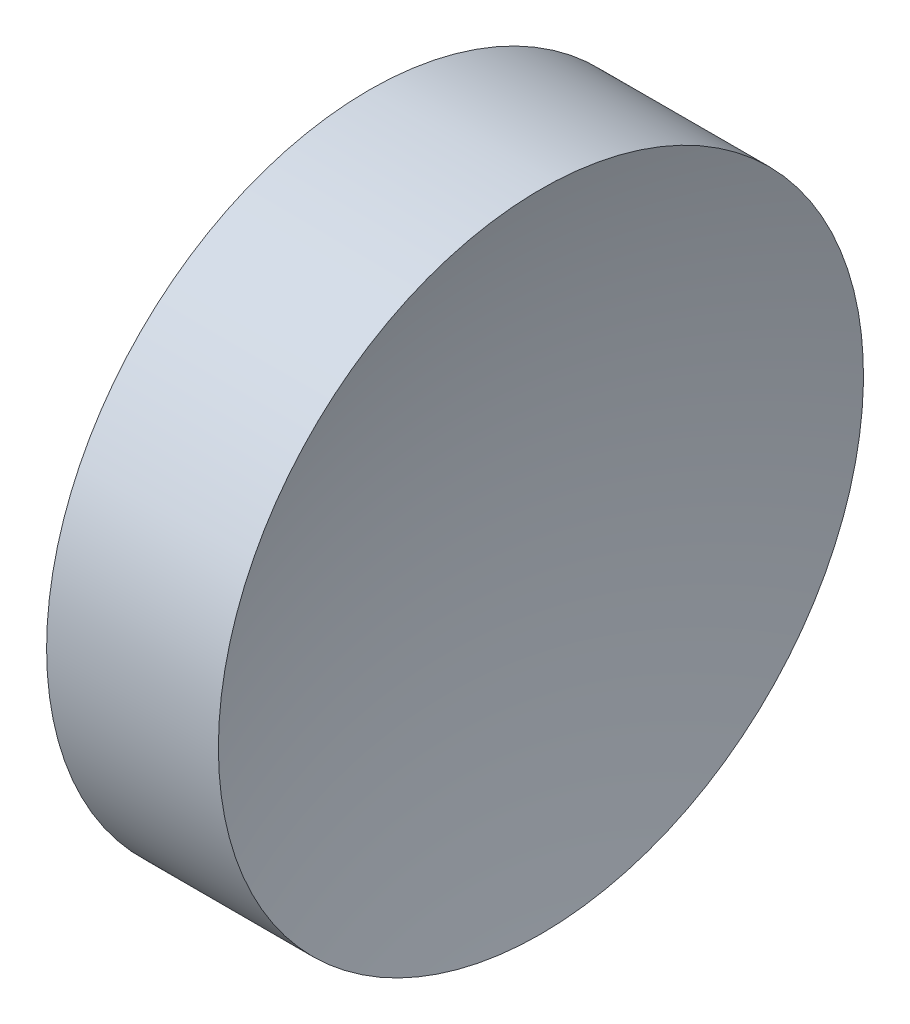
from build123d import *


with BuildPart() as part:
    # 草图2 → 旋转1 (revolve)
    with BuildSketch(Plane.XY, mode=Mode.PRIVATE) as revolve_1_sk:
        with BuildLine():
            Line((94.590443968, 52.178082298), (97.590443968, 52.178082298))
            ThreePointArc((97.590443968, 52.178082298), (98.063404259, 58.597399239), (99.472070908, 64.878082298))
            Line((99.472070908, 64.878082298), (96.090443968, 64.878082298))
            Line((96.090443968, 64.878082298), (92.708817028, 64.878082298))
            ThreePointArc((92.708817028, 64.878082298), (94.117483678, 58.597399239), (94.590443968, 52.178082298))
        make_face()
    revolve(revolve_1_sk.sketch.rotate(Axis((84.899722228, 52.178082298, 0), (1, 0, 0)), 90), axis=Axis((84.899722228, 52.178082298, 0), (1, 0, 0)))  # turned: the seam where the file's is


solid = part.part
